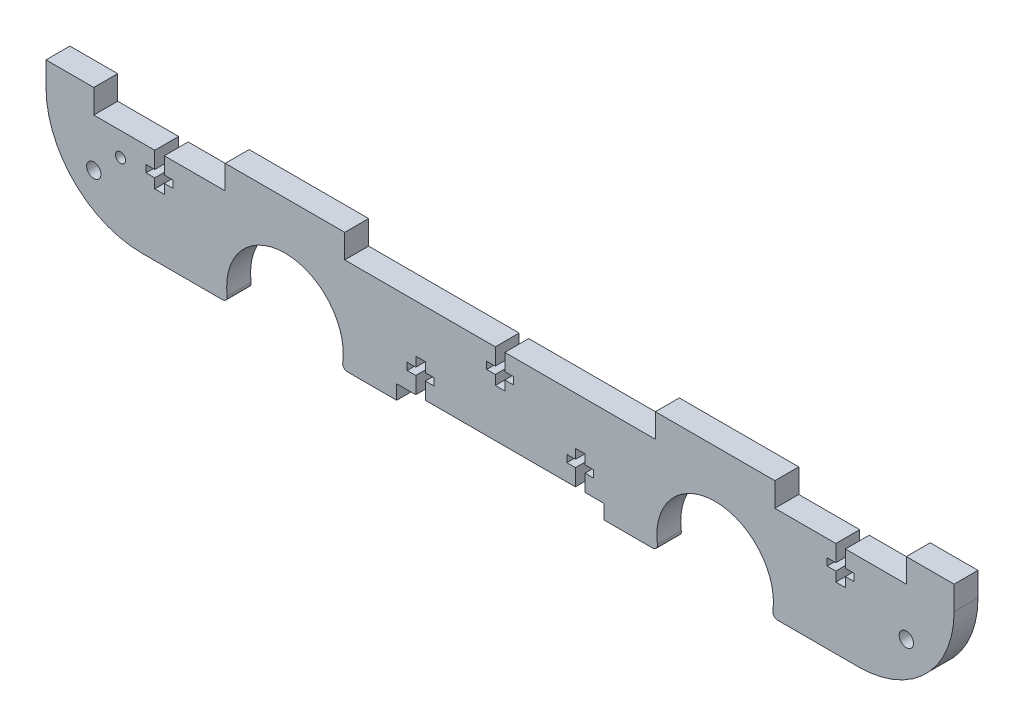
from build123d import *

# Parameters (mm, degrees)
RESSALTO_EXTRUS_O1_DEPTH = 5
ESBO_O2_R                = 12.2
CORTE_EXTRUS_O1_DEPTH    = 6
FILETE1_R                = 1
ESBO_O3_W                = 27.5
ESBO_O3_H                = 5
ESBO_O3_W_2              = 65
CORTE_EXTRUS_O2_DEPTH    = 6
CORTE_EXTRUS_O3_DEPTH    = 6
ESBO_O5_R                = 1.5
ESBO_O5_R_2              = 1.036414637
CORTE_EXTRUS_O4_DEPTH    = 6
ESBO_O6_W                = 43.400181399
ESBO_O6_H                = 3
CORTE_EXTRUS_O5_DEPTH    = 6


with BuildPart() as part:
    # Esboço1 → Ressalto-extrusão1 (new body)
    with BuildSketch(Plane.XY):
        with BuildLine():
            Line((20, 0), (170, 0))
            ThreePointArc((170, 0), (184.142135624, 5.857864376), (190, 20))
            Line((190, 20), (190, 25))
            Line((190, 25), (0, 25))
            Line((0, 25), (0, 20))
            ThreePointArc((0, 20), (5.857864376, 5.857864376), (20, 0))
        make_face()
    extrude(amount=RESSALTO_EXTRUS_O1_DEPTH)

    # Esboço2 → Corte-extrusão1 (cut, through all)
    with BuildSketch(Plane(origin=(0, 0, 0), x_dir=(-1, 0, 0), z_dir=(0, 0, -1))):
        with Locations((-50, 2.8)):
            Circle(ESBO_O2_R)
        with Locations((-140, 2.8)):
            Circle(ESBO_O2_R)
    extrude(amount=-CORTE_EXTRUS_O1_DEPTH, mode=Mode.SUBTRACT)

    # Filete1
    filete1_edges = [part.edges().sort_by_distance(p)[0] for p in [
        (61.874342087, 0, 2.5),
        (38.125657913, 0, 2.5),
        (151.874342087, 0, 2.5),
        (128.125657913, 0, 2.5),
    ]]
    fillet(filete1_edges, radius=FILETE1_R)

    # Esboço3 → Corte-extrusão2 (cut, through all)
    with BuildSketch(Plane(origin=(0, 0, 0), x_dir=(-1, 0, 0), z_dir=(0, 0, -1))):
        with Locations((-166.25, 22.5)):
            Rectangle(ESBO_O3_W, ESBO_O3_H)
        with Locations((-95, 22.5)):
            Rectangle(ESBO_O3_W_2, ESBO_O3_H)
        with Locations((-23.75, 22.5)):
            Rectangle(ESBO_O3_W, ESBO_O3_H)
    extrude(amount=-CORTE_EXTRUS_O2_DEPTH, mode=Mode.SUBTRACT)

    # Esboço4 → Corte-extrusão3 (cut, through all)
    with BuildSketch(Plane(origin=(0, 0, 0), x_dir=(-1, 0, 0), z_dir=(0, 0, -1))):
        Polygon((-24.75, 13), (-24.75, 15), (-26.55, 15), (-26.55, 16.5), (-24.75, 16.5), (-24.75, 20), (-22.75, 20), (-22.75, 16.5), (-20.95, 16.5), (-20.95, 15), (-22.75, 15), (-22.75, 13), align=None)
        Polygon((-96, 13), (-96, 15), (-97.8, 15), (-97.8, 16.5), (-96, 16.5), (-96, 20), (-94, 20), (-94, 16.5), (-92.2, 16.5), (-92.2, 15), (-94, 15), (-94, 13), align=None)
        Polygon((-167.25, 13), (-167.25, 15), (-169.05, 15), (-169.05, 16.5), (-167.25, 16.5), (-167.25, 20), (-165.25, 20), (-165.25, 16.5), (-163.45, 16.5), (-163.45, 15), (-165.25, 15), (-165.25, 13), align=None)
    extrude(amount=-CORTE_EXTRUS_O3_DEPTH, mode=Mode.SUBTRACT)

    # Esboço5 → Corte-extrusão4 (cut, through all)
    with BuildSketch(Plane.XY.offset(5)):
        with Locations((180, 10)):
            Circle(ESBO_O5_R)
        with Locations((10, 10)):
            Circle(ESBO_O5_R)
        with Locations((15.588408084, 15.09127059)):
            Circle(ESBO_O5_R_2)
    extrude(amount=-CORTE_EXTRUS_O4_DEPTH, mode=Mode.SUBTRACT)

    # Esboço6 → Corte-extrusão5 (cut, through all)
    with BuildSketch(Plane.XY.offset(5)):
        Polygon((77.369700901, 6.5), (77.369700901, 3), (79.369700901, 3), (79.369700901, 6.5), (81.169700901, 6.5), (81.169700901, 8), (79.369700901, 8), (79.369700901, 10), (77.369700901, 10), (77.369700901, 8), (75.569700901, 8), (75.569700901, 6.5), align=None)
        with Locations((95.0697916, 1.5)):
            Rectangle(ESBO_O6_W, ESBO_O6_H)
        Polygon((110.7698823, 3), (112.7698823, 3), (112.7698823, 6.5), (114.5698823, 6.5), (114.5698823, 8), (112.7698823, 8), (112.7698823, 10), (110.7698823, 10), (110.7698823, 8), (108.9698823, 8), (108.9698823, 6.5), (110.7698823, 6.5), align=None)
    extrude(amount=-CORTE_EXTRUS_O5_DEPTH, mode=Mode.SUBTRACT)


solid = part.part
